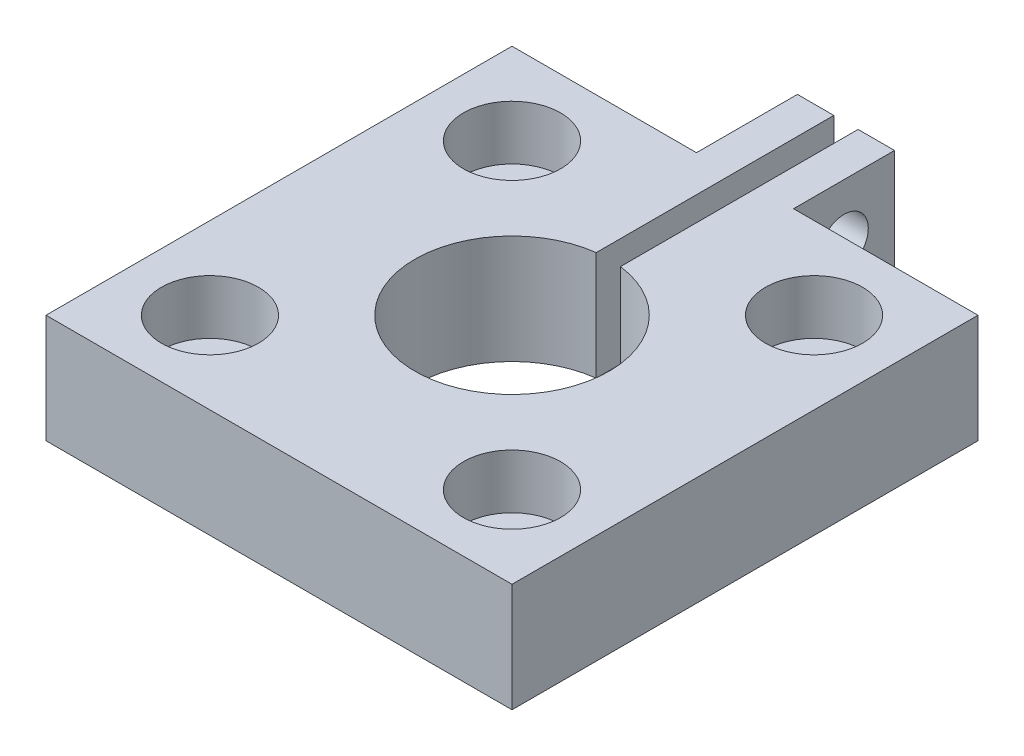
from build123d import *

# Parameters (mm, degrees)
SKETCH1_R                                  = 3.175
BOSS_EXTRUDE1_DEPTH                        = 3.556
SKETCH2_R                                  = 0.79375
CUT_EXTRUDE1_DEPTH                         = 4.556
SKETCH3_R                                  = 0.79375
CUT_EXTRUDE2_DEPTH                         = 3.175
SKETCH4_W                                  = 0.79375
SKETCH4_H                                  = 4.469902345
CUT_EXTRUDE3_DEPTH                         = 4.556
SKETCH5_R                                  = 1.5875
CUT_EXTRUDE4_DEPTH                         = 1.778
MIRROR1_AT_THE_SECOND_PLANE_COPY_1_SKETC_R = 1.5875
MIRROR1_AT_THE_SECOND_PLANE_COPY_1_DEPTH   = 1.778


with BuildPart() as part:
    # Sketch1 → Boss-Extrude1 (new body)
    with BuildSketch(Plane(origin=(0, 0, 0), x_dir=(1, 0, 0), z_dir=(0, 1, 0))):
        Polygon((-1.5875, 7.62), (-1.5875, 10.922), (-0.396875, 10.922), (-0.396875, 7.62), (0.396875, 7.62), (0.396875, 10.922), (1.5875, 10.922), (1.5875, 7.62), (7.62, 7.62), (7.62, -7.62), (-7.62, -7.62), (-7.62, 7.62), align=None)
        Circle(SKETCH1_R, mode=Mode.SUBTRACT)
    extrude(amount=BOSS_EXTRUDE1_DEPTH)

    # Sketch2 → Cut-Extrude1 (cut, through all)
    with BuildSketch(Plane(origin=(0, 3.556, 0), x_dir=(1, 0, 0), z_dir=(0, 1, 0))):
        with Locations((-4.939140867, 4.939140867)):
            Circle(SKETCH2_R)
        with Locations((4.939140867, 4.939140867)):
            Circle(SKETCH2_R)
        with Locations((4.939140867, -4.939140867)):
            Circle(SKETCH2_R)
        with Locations((-4.939140867, -4.939140867)):
            Circle(SKETCH2_R)
    extrude(amount=-CUT_EXTRUDE1_DEPTH, mode=Mode.SUBTRACT)

    # Sketch3 → Cut-Extrude2 (cut)
    with BuildSketch(Plane(origin=(1.5875, 0, 0), x_dir=(0, 0, -1), z_dir=(1, 0, 0))):
        with Locations((9.271, 1.778)):
            Circle(SKETCH3_R)
    extrude(amount=-CUT_EXTRUDE2_DEPTH, mode=Mode.SUBTRACT)

    # Sketch4 → Cut-Extrude3 (cut, through all)
    with BuildSketch(Plane(origin=(0, 3.556, 0), x_dir=(1, 0, 0), z_dir=(0, 1, 0))):
        with Locations((0, 5.385048828)):
            Rectangle(SKETCH4_W, SKETCH4_H)
    extrude(amount=-CUT_EXTRUDE3_DEPTH, mode=Mode.SUBTRACT)

    # Sketch5 → Cut-Extrude4 (cut)
    with BuildSketch(Plane(origin=(0, 3.556, 0), x_dir=(1, 0, 0), z_dir=(0, 1, 0))):
        with Locations((-4.939140867, 4.939140867)):
            Circle(SKETCH5_R)
    cut_extrude4 = extrude(amount=-CUT_EXTRUDE4_DEPTH, mode=Mode.SUBTRACT)

    # Mirror1: Cut-Extrude4 across plane
    add(cut_extrude4.mirror(Plane.XY), mode=Mode.SUBTRACT)

    # Mirror1 at the second plane: Cut-Extrude4 across plane
    add(cut_extrude4.mirror(Plane(origin=(0, 0, 0), x_dir=(0, 0, 1), z_dir=(1, 0, 0))), mode=Mode.SUBTRACT)

    # Mirror1 at the second plane copy 1 sketc → Mirror1 at the second plane copy 1 (cut)
    with BuildSketch(Plane(origin=(0, 3.556, 0), x_dir=(-1, 0, 0), z_dir=(0, 1, 0))):
        with Locations((-4.939140867, 4.939140867)):
            Circle(MIRROR1_AT_THE_SECOND_PLANE_COPY_1_SKETC_R)
    extrude(amount=-MIRROR1_AT_THE_SECOND_PLANE_COPY_1_DEPTH, mode=Mode.SUBTRACT)


solid = part.part
